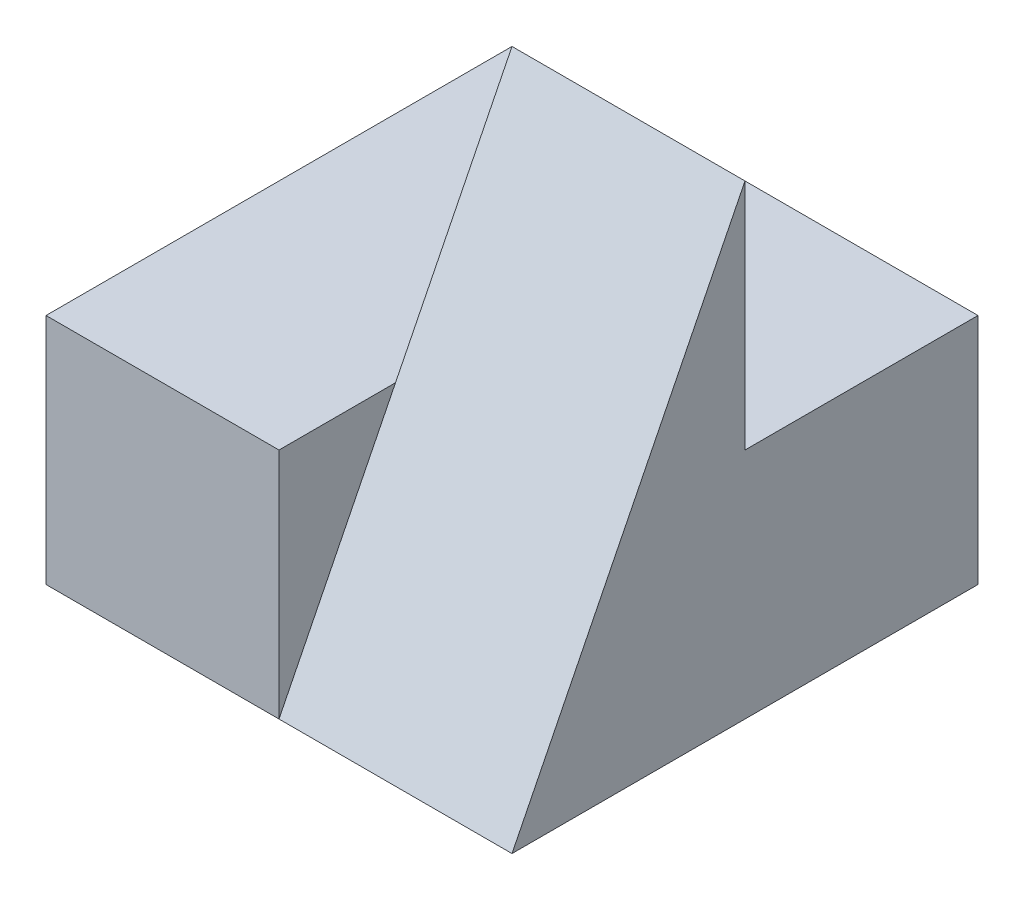
from build123d import *

# Parameters (mm, degrees)
SKETCH1_W           = 4
SKETCH1_H           = 4
BOSS_EXTRUDE1_DEPTH = 4
CUT_EXTRUDE1_DEPTH  = 2
CUT_EXTRUDE2_DEPTH  = 2


with BuildPart() as part:
    # Sketch1 → Boss-Extrude1 (new body)
    with BuildSketch(Plane(origin=(0, 0, 0), x_dir=(1, 0, 0), z_dir=(0, 1, 0))):
        with Locations((2, 2)):
            Rectangle(SKETCH1_W, SKETCH1_H)
    extrude(amount=BOSS_EXTRUDE1_DEPTH)

    # Sketch2 → Cut-Extrude1 (cut)
    with BuildSketch(Plane(origin=(0, 4, 0), x_dir=(1, 0, 0), z_dir=(0, 1, 0))):
        Polygon((2, 0), (2, 2), (4, 2), (4, 4), (0, 4), (0, 0), align=None)
    extrude(amount=-CUT_EXTRUDE1_DEPTH, mode=Mode.SUBTRACT)

    # Sketch3 → Cut-Extrude2 (cut)
    with BuildSketch(Plane(origin=(4, 0, 0), x_dir=(0, 0, -1), z_dir=(1, 0, 0))):
        Polygon((2, 4), (0, 0), (0, 4), align=None)
    extrude(amount=-CUT_EXTRUDE2_DEPTH, mode=Mode.SUBTRACT)


solid = part.part
